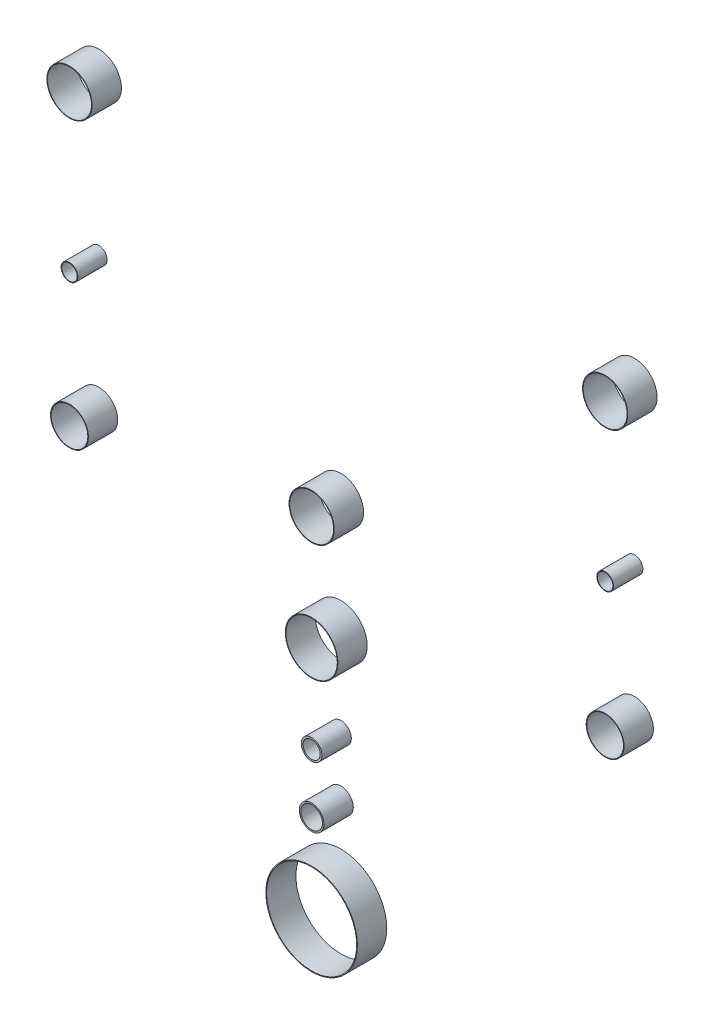
from build123d import *

# Parameters (mm, degrees)
SKETCH1_R         = 312
SKETCH1_R_2       = 307
EXTRUDE1_DEPTH    = 200
SKETCH1_R_3       = 84
SKETCH1_R_4       = 74
EXTRUDE1_2_DEPTH  = 200
SKETCH1_R_5       = 70.5
SKETCH1_R_6       = 58.5
EXTRUDE1_3_DEPTH  = 200
SKETCH1_R_7       = 179
SKETCH1_R_8       = 175
EXTRUDE1_4_DEPTH  = 200
SKETCH1_R_9       = 154
SKETCH1_R_10      = 150
EXTRUDE1_5_DEPTH  = 200
EXTRUDE1_6_DEPTH  = 200
SKETCH1_R_11      = 57
SKETCH1_R_12      = 53
EXTRUDE1_7_DEPTH  = 200
SKETCH1_R_13      = 129
SKETCH1_R_14      = 125
EXTRUDE1_8_DEPTH  = 200
EXTRUDE1_9_DEPTH  = 200
EXTRUDE1_10_DEPTH = 200
EXTRUDE1_11_DEPTH = 200


with BuildPart() as part:
    # Sketch1 → Extrude1 (new body)
    with BuildSketch(Plane.XY):
        with Locations((-2750, -16925)):
            Circle(SKETCH1_R)
        with Locations((-2750, -16925)):
            Circle(SKETCH1_R_2, mode=Mode.SUBTRACT)
    extrude(amount=EXTRUDE1_DEPTH)


with BuildPart() as body_2:
    # Sketch1 → Extrude1 2 (new body)
    with BuildSketch(Plane.XY):
        with Locations((-2750, -16325)):
            Circle(SKETCH1_R_3)
        with Locations((-2750, -16325)):
            Circle(SKETCH1_R_4, mode=Mode.SUBTRACT)
    extrude(amount=EXTRUDE1_2_DEPTH)


with BuildPart() as body_3:
    # Sketch1 → Extrude1 3 (new body)
    with BuildSketch(Plane.XY):
        with Locations((-2750, -15925)):
            Circle(SKETCH1_R_5)
        with Locations((-2750, -15925)):
            Circle(SKETCH1_R_6, mode=Mode.SUBTRACT)
    extrude(amount=EXTRUDE1_3_DEPTH)


with BuildPart() as body_4:
    # Sketch1 → Extrude1 4 (new body)
    with BuildSketch(Plane.XY):
        with Locations((-2750, -15325)):
            Circle(SKETCH1_R_7)
        with Locations((-2750, -15325)):
            Circle(SKETCH1_R_8, mode=Mode.SUBTRACT)
    extrude(amount=EXTRUDE1_4_DEPTH)


with BuildPart() as body_5:
    # Sketch1 → Extrude1 5 (new body)
    with BuildSketch(Plane.XY):
        with Locations((-2750, -14550)):
            Circle(SKETCH1_R_9)
        with Locations((-2750, -14550)):
            Circle(SKETCH1_R_10, mode=Mode.SUBTRACT)
    extrude(amount=EXTRUDE1_5_DEPTH)


with BuildPart() as body_6:
    # Sketch1 → Extrude1 6 (new body)
    with BuildSketch(Plane.XY):
        with Locations((-750, -12870.955169581)):
            Circle(SKETCH1_R_9)
        with Locations((-750, -12870.955169581)):
            Circle(SKETCH1_R_10, mode=Mode.SUBTRACT)
    extrude(amount=EXTRUDE1_6_DEPTH)


with BuildPart() as body_7:
    # Sketch1 → Extrude1 7 (new body)
    with BuildSketch(Plane.XY):
        with Locations((-750, -13933.051127446)):
            Circle(SKETCH1_R_11)
        with Locations((-750, -13933.051127446)):
            Circle(SKETCH1_R_12, mode=Mode.SUBTRACT)
    extrude(amount=EXTRUDE1_7_DEPTH)


with BuildPart() as body_8:
    # Sketch1 → Extrude1 8 (new body)
    with BuildSketch(Plane.XY):
        with Locations((-750, -14841.326291413)):
            Circle(SKETCH1_R_13)
        with Locations((-750, -14841.326291413)):
            Circle(SKETCH1_R_14, mode=Mode.SUBTRACT)
    extrude(amount=EXTRUDE1_8_DEPTH)


with BuildPart() as body_9:
    # Sketch1 → Extrude1 9 (new body)
    with BuildSketch(Plane.XY):
        with Locations((-4400, -14841.326291413)):
            Circle(SKETCH1_R_13)
        with Locations((-4400, -14841.326291413)):
            Circle(SKETCH1_R_14, mode=Mode.SUBTRACT)
    extrude(amount=EXTRUDE1_9_DEPTH)


with BuildPart() as body_10:
    # Sketch1 → Extrude1 10 (new body)
    with BuildSketch(Plane.XY):
        with Locations((-4400, -13933.051127446)):
            Circle(SKETCH1_R_11)
        with Locations((-4400, -13933.051127446)):
            Circle(SKETCH1_R_12, mode=Mode.SUBTRACT)
    extrude(amount=EXTRUDE1_10_DEPTH)


with BuildPart() as body_11:
    # Sketch1 → Extrude1 11 (new body)
    with BuildSketch(Plane.XY):
        with Locations((-4400, -12870.955169581)):
            Circle(SKETCH1_R_9)
        with Locations((-4400, -12870.955169581)):
            Circle(SKETCH1_R_10, mode=Mode.SUBTRACT)
    extrude(amount=EXTRUDE1_11_DEPTH)


solid = Compound([part.part, body_2.part, body_3.part, body_4.part, body_5.part, body_6.part, body_7.part, body_8.part, body_9.part, body_10.part, body_11.part])
